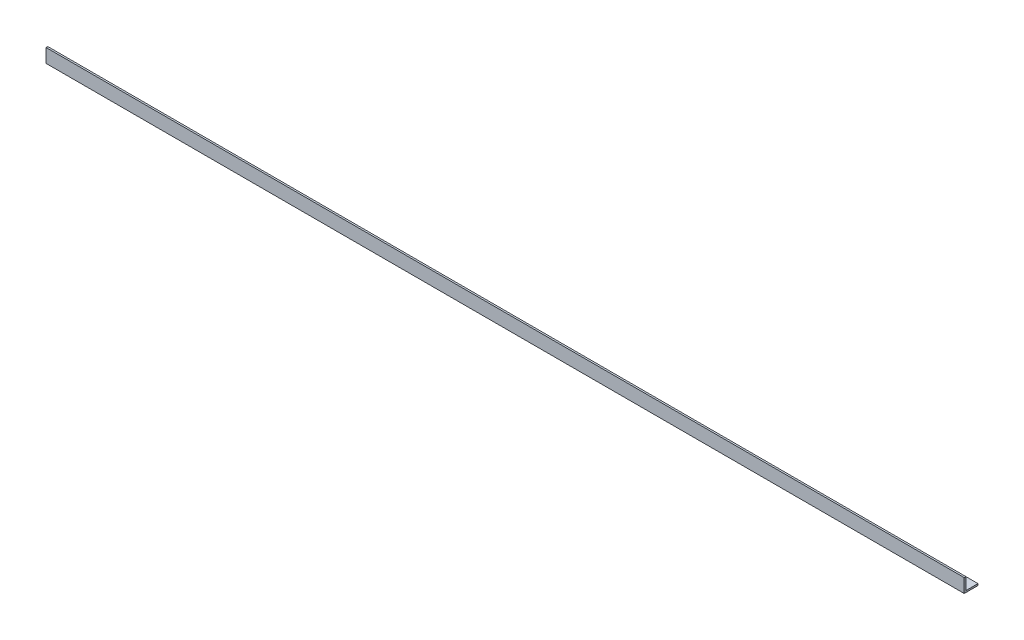
from build123d import *

# Parameters (mm, degrees)
EXTRUDE_1_DEPTH = 2665


with BuildPart() as part:
    # Эскиз1 → Вытянуть-Тонкостенный1 (new body)
    with BuildSketch(Plane(origin=(0, 0, 0), x_dir=(0, 0, -1), z_dir=(1, 0, 0))):
        Polygon((0, 40), (0, 0), (40, 0), (40, 5), (5, 5), (5, 40), align=None)
    extrude(amount=EXTRUDE_1_DEPTH)


solid = part.part
